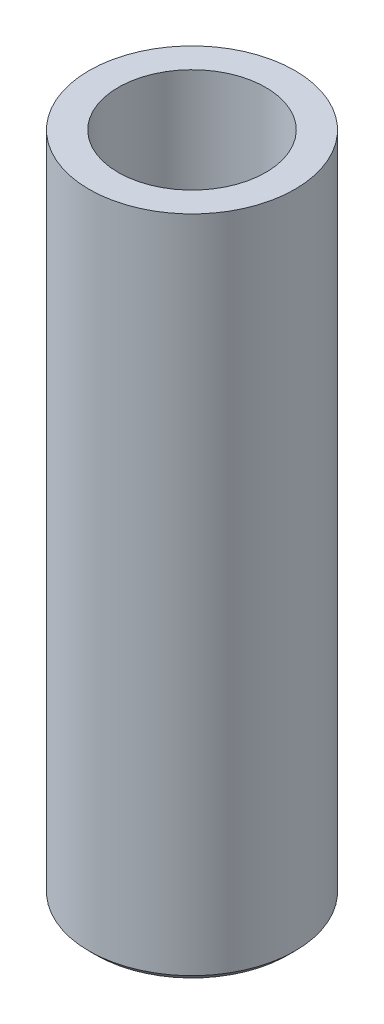
from build123d import *

# Parameters (mm, degrees)
SKETCH1_R           = 6
BOSS_EXTRUDE1_DEPTH = 1
SKETCH2_R           = 6
SKETCH2_R_2         = 4.3
BOSS_EXTRUDE2_DEPTH = 37.86
CHAMFER1_SIZE       = 0.4


with BuildPart() as part:
    # Sketch1 → Boss-Extrude1 (new body)
    with BuildSketch(Plane(origin=(0, 0, 0), x_dir=(1, 0, 0), z_dir=(0, 1, 0))):
        Circle(SKETCH1_R)
    extrude(amount=BOSS_EXTRUDE1_DEPTH)

    # Sketch2 → Boss-Extrude2 (add)
    with BuildSketch(Plane(origin=(0, 1, 0), x_dir=(1, 0, 0), z_dir=(0, 1, 0))):
        Circle(SKETCH2_R)
        Circle(SKETCH2_R_2, mode=Mode.SUBTRACT)
    extrude(amount=BOSS_EXTRUDE2_DEPTH)

    # Chamfer1
    chamfer1_edges = [part.edges().sort_by_distance(p)[0] for p in [
        (-6, 0, 0),
    ]]
    chamfer(chamfer1_edges, length=CHAMFER1_SIZE)


solid = part.part
